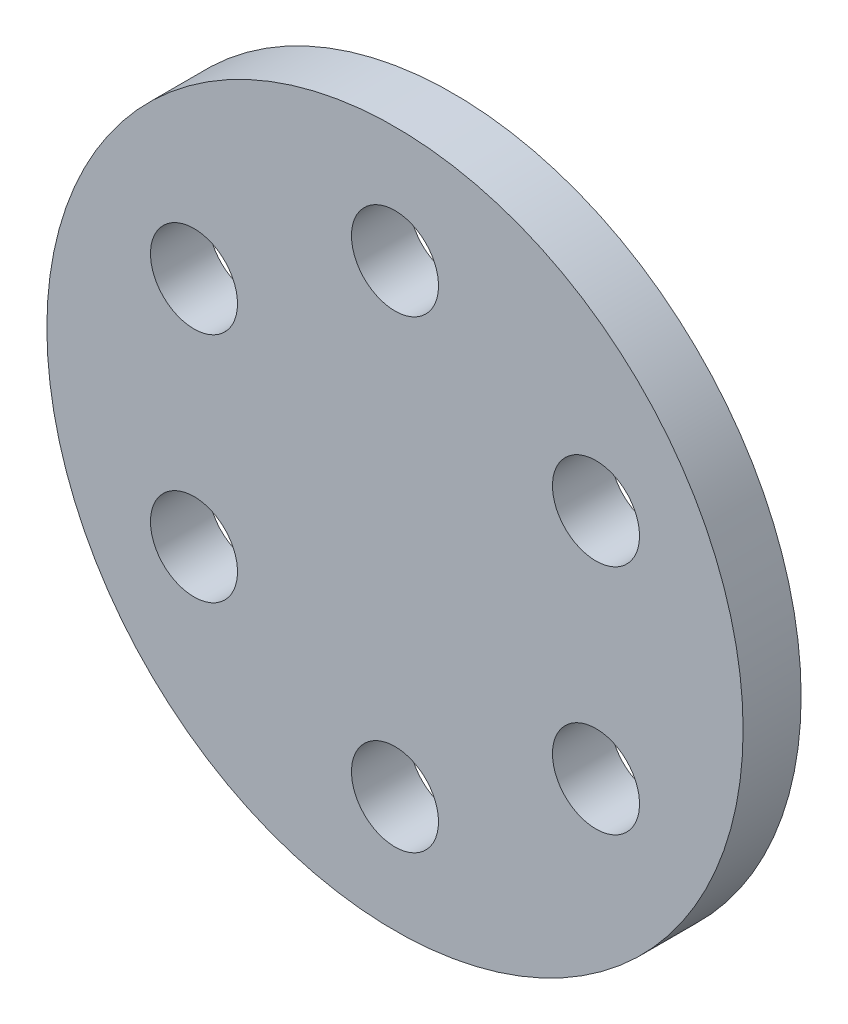
from build123d import *

# Parameters (mm, degrees)
SKICA1_R                 = 60
VYSUNOUT1_DEPTH          = 10
SKICA7_R                 = 7.5
ODEBRAT_VYSUNUT_M1_DEPTH = 11
KRUHOV_POLE1_COUNT       = 6


with BuildPart() as part:
    # Skica1 → Vysunout1 (new body)
    with BuildSketch(Plane.XY):
        Circle(SKICA1_R)
    extrude(amount=VYSUNOUT1_DEPTH)

    # Skica7 → Odebrat vysunutím1 (cut, through all)
    with BuildSketch(Plane(origin=(0, 0, 0), x_dir=(-1, 0, 0), z_dir=(0, 0, -1))):
        with Locations((0, 40)):
            Circle(SKICA7_R)
    odebrat_vysunut_m1 = extrude(amount=-ODEBRAT_VYSUNUT_M1_DEPTH, mode=Mode.SUBTRACT)

    # Kruhové pole1: Odebrat vysunutím1 ×6 about axis
    kruhov_pole1_axis = Axis((0, 0, 0), (0, 0, 1))
    for i in range(1, KRUHOV_POLE1_COUNT):
        add(odebrat_vysunut_m1.rotate(kruhov_pole1_axis, i * 360 / KRUHOV_POLE1_COUNT), mode=Mode.SUBTRACT)


solid = part.part
